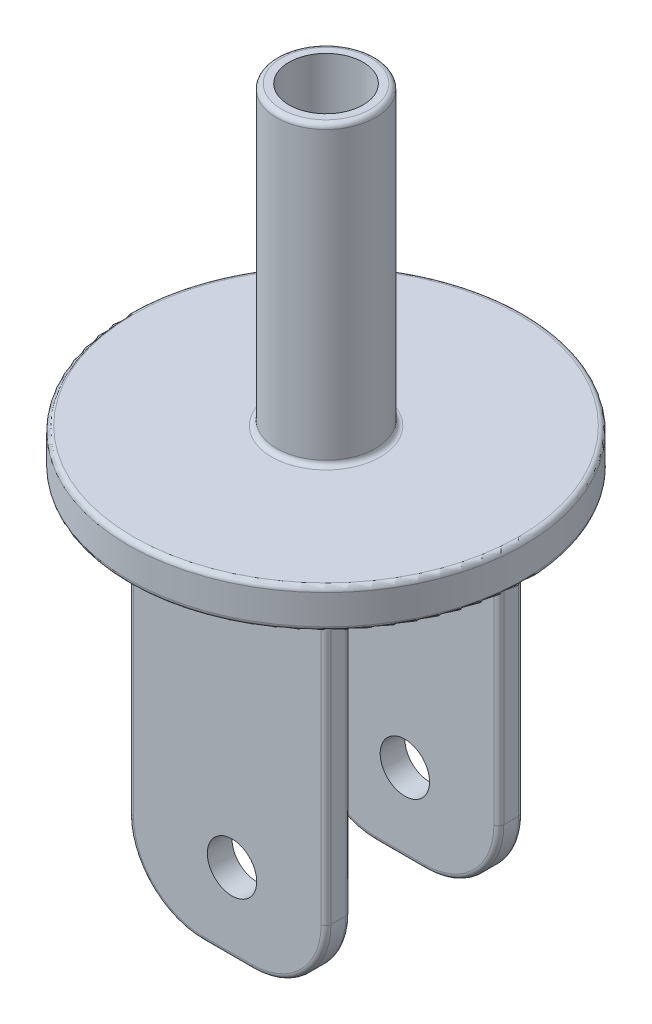
from build123d import *

# Parameters (mm, degrees)
SKETCH2_R             = 40
BOSS_EXTRUDE1_DEPTH   = 8
SKETCH3_W             = 40
SKETCH3_H             = 5
BOSS_EXTRUDE2_DEPTH   = 75
FILLET1_R             = 15
FILLET3_R             = 1
FILLET4_R             = 4
FILLET1_OF_MIRROR10_R = 15
FILLET3_OF_MIRROR10_R = 1
FILLET4_OF_MIRROR10_R = 4
SKETCH5_R             = 5
CUT_EXTRUDE1_DEPTH    = 40
SKETCH6_R             = 10
BOSS_EXTRUDE3_DEPTH   = 60
SKETCH7_R             = 7.5
CUT_EXTRUDE2_DEPTH    = 60
FILLET5_R             = 1


with BuildPart() as part:
    # Sketch2 → Boss-Extrude1 (new body)
    with BuildSketch(Plane(origin=(0, 0, 0), x_dir=(1, 0, 0), z_dir=(0, 1, 0))):
        Circle(SKETCH2_R)
    extrude(amount=BOSS_EXTRUDE1_DEPTH)

    # Sketch3 → Boss-Extrude2 (add)
    with BuildSketch(Plane.XZ):
        with Locations((0, -17.5)):
            Rectangle(SKETCH3_W, SKETCH3_H)
    boss_extrude2 = extrude(amount=BOSS_EXTRUDE2_DEPTH)

    # Fillet1
    fillet1_edges = [part.edges().sort_by_distance(p)[0] for p in [
        (-20, -75, -17.5),
        (20, -75, -17.5),
    ]]
    fillet(fillet1_edges, radius=FILLET1_R)

    # Fillet3
    fillet3_edges = [part.edges().sort_by_distance(p)[0] for p in [
        (0, -75, -20),
        (0, -75, -15),
        (20, -30, -20),
        (-20, -30, -20),
        (15.606601718, -70.606601718, -20),
        (-15.606601718, -70.606601718, -20),
        (-20, -30, -15),
        (20, -30, -15),
        (15.606601718, -70.606601718, -15),
        (-15.606601718, -70.606601718, -15),
    ]]
    fillet(fillet3_edges, radius=FILLET3_R)

    # Fillet4
    fillet4_edges = [part.edges().sort_by_distance(p)[0] for p in [
        (-20, 0, -17.5),
        (0, 0, -15),
        (20, 0, -17.5),
        (0, 0, -20),
        (-19.707106781, 0, -15.292893219),
        (19.707106781, 0, -15.292893219),
        (19.707106781, 0, -19.707106781),
        (-19.707106781, 0, -19.707106781),
    ]]
    fillet(fillet4_edges, radius=FILLET4_R)

    # Mirror10: Boss-Extrude2 across plane
    add(boss_extrude2.mirror(Plane.XY))

    # Fillet1 of Mirror10
    fillet1_of_mirror10_edges = [part.edges().sort_by_distance(p)[0] for p in [
        (-20, -75, 17.5),
        (20, -75, 17.5),
    ]]
    fillet(fillet1_of_mirror10_edges, radius=FILLET1_OF_MIRROR10_R)

    # Fillet3 of Mirror10
    fillet3_of_mirror10_edges = [part.edges().sort_by_distance(p)[0] for p in [
        (0, -75, 20),
        (0, -75, 15),
        (20, -30, 20),
        (-20, -30, 20),
        (15.606601718, -70.606601718, 20),
        (-15.606601718, -70.606601718, 20),
        (-20, -30, 15),
        (20, -30, 15),
        (15.606601718, -70.606601718, 15),
        (-15.606601718, -70.606601718, 15),
    ]]
    fillet(fillet3_of_mirror10_edges, radius=FILLET3_OF_MIRROR10_R)

    # Fillet4 of Mirror10
    fillet4_of_mirror10_edges = [part.edges().sort_by_distance(p)[0] for p in [
        (-20, 0, 17.5),
        (0, 0, 15),
        (20, 0, 17.5),
        (0, 0, 20),
        (-19.707106781, 0, 15.292893219),
        (19.707106781, 0, 15.292893219),
        (19.707106781, 0, 19.707106781),
        (-19.707106781, 0, 19.707106781),
    ]]
    fillet(fillet4_of_mirror10_edges, radius=FILLET4_OF_MIRROR10_R)

    # Sketch5 → Cut-Extrude1 (cut)
    with BuildSketch(Plane(origin=(0, 0, -20), x_dir=(-1, 0, 0), z_dir=(0, 0, -1))):
        with Locations((-0.961594328, -59)):
            Circle(SKETCH5_R)
    extrude(amount=-CUT_EXTRUDE1_DEPTH, mode=Mode.SUBTRACT)

    # Sketch6 → Boss-Extrude3 (add)
    with BuildSketch(Plane(origin=(0, 8, 0), x_dir=(1, 0, 0), z_dir=(0, 1, 0))):
        Circle(SKETCH6_R)
    extrude(amount=BOSS_EXTRUDE3_DEPTH)

    # Sketch7 → Cut-Extrude2 (cut)
    with BuildSketch(Plane(origin=(0, 68, 0), x_dir=(1, 0, 0), z_dir=(0, 1, 0))):
        Circle(SKETCH7_R)
    extrude(amount=-CUT_EXTRUDE2_DEPTH, mode=Mode.SUBTRACT)

    # Fillet5
    fillet5_edges = [part.edges().sort_by_distance(p)[0] for p in [
        (-10, 8, 0),
        (-10, 68, 0),
        (-40, 0, 0),
        (-40, 8, 0),
    ]]
    fillet(fillet5_edges, radius=FILLET5_R)


solid = part.part
